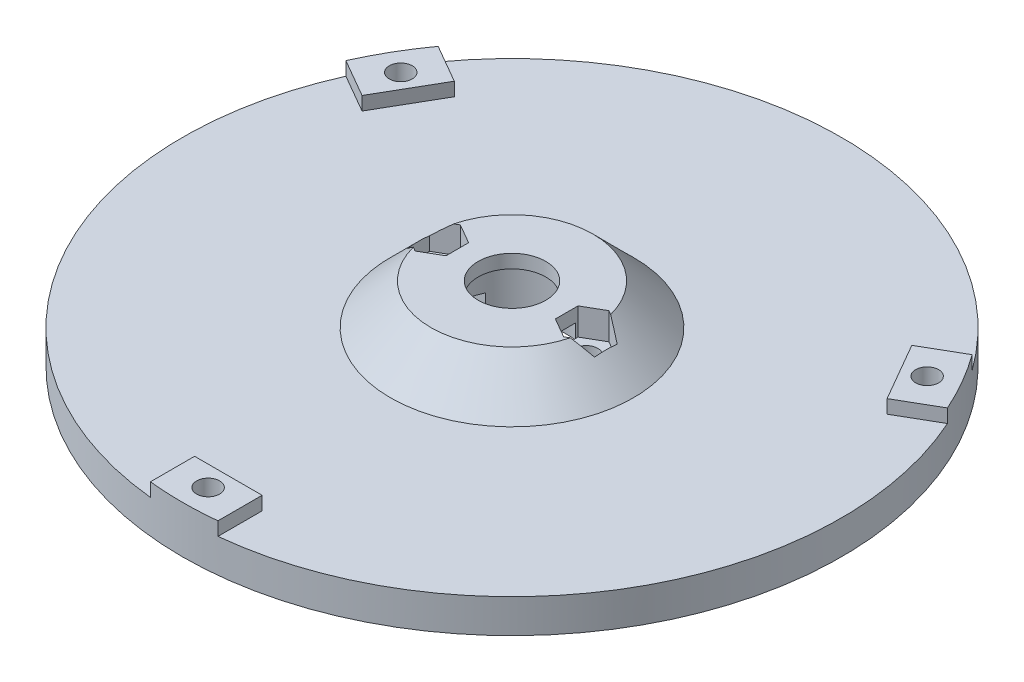
from build123d import *

# Parameters (mm, degrees)
CROQUIS2_W              = 30.6
CROQUIS2_H              = 7
CORTAR_EXTRUIR1_DEPTH   = 4
CROQUIS3_R              = 1.7
CORTAR_EXTRUIR2_DEPTH   = 13
CORTAR_EXTRUIR3_DEPTH   = 4
SALIENTE_EXTRUIR1_DEPTH = 2
CROQUIS6_R              = 1.7
CORTAR_EXTRUIR4_DEPTH   = 9
CROQUIS7_R              = 2.95
CORTAR_EXTRUIR5_DEPTH   = 3
MATRIZC1_COUNT          = 3


with BuildPart() as part:
    # Croquis1 → Revolución1 (revolve)
    with BuildSketch(Plane.XY):
        Polygon((5, 11), (12, 11), (18, 5), (48.8, 5), (48.8, 0), (8.2, 0), (8.2, 9), (5, 9), align=None)
    revolve(axis=Axis((0, 21.109727454, 0), (0, -1, 0)))

    # Croquis2 → Cortar-Extruir1 (cut)
    with BuildSketch(Plane.XZ):
        Rectangle(CROQUIS2_W, CROQUIS2_H)
    extrude(amount=-CORTAR_EXTRUIR1_DEPTH, mode=Mode.SUBTRACT)

    # Croquis3 → Cortar-Extruir2 (cut)
    with BuildSketch(Plane.XZ.offset(-4)):
        with Locations((-11, 0)):
            Circle(CROQUIS3_R)
        with Locations((11, 0)):
            Circle(CROQUIS3_R)
    extrude(amount=-CORTAR_EXTRUIR2_DEPTH, mode=Mode.SUBTRACT)

    # Croquis4 → Cortar-Extruir3 (cut)
    with BuildSketch(Plane(origin=(0, 11, 0), x_dir=(1, 0, 0), z_dir=(0, 1, 0))):
        Polygon((-11, 3.35), (-13.901185103, 1.675), (-13.901185103, -1.675), (-11, -3.35), (-8.098814897, -1.675), (-8.098814897, 1.675), align=None)
        Polygon((11, 3.35), (8.098814897, 1.675), (8.098814897, -1.675), (11, -3.35), (13.901185103, -1.675), (13.901185103, 1.675), align=None)
    extrude(amount=-CORTAR_EXTRUIR3_DEPTH, mode=Mode.SUBTRACT)

    # Croquis5 → Saliente-Extruir1 (add)
    with BuildSketch(Plane(origin=(0, 5, 0), x_dir=(1, 0, 0), z_dir=(0, 1, 0))):
        with BuildLine():
            Line((5, -42), (-5, -42))
            Line((-5, -42), (-5, -48.543176657))
            ThreePointArc((-5, -48.543176657), (0, -48.8), (5, -48.543176657))
            Line((5, -48.543176657), (5, -42))
        make_face()
    saliente_extruir1 = extrude(amount=SALIENTE_EXTRUIR1_DEPTH)

    # Croquis6 → Cortar-Extruir4 (cut)
    with BuildSketch(Plane(origin=(0, 7, 0), x_dir=(1, 0, 0), z_dir=(0, 1, 0))):
        with Locations((0, -45)):
            Circle(CROQUIS6_R)
    cortar_extruir4 = extrude(amount=-CORTAR_EXTRUIR4_DEPTH, mode=Mode.SUBTRACT)

    # Croquis7 → Cortar-Extruir5 (cut)
    with BuildSketch(Plane.XZ):
        with Locations((0, 45)):
            Circle(CROQUIS7_R)
    cortar_extruir5 = extrude(amount=-CORTAR_EXTRUIR5_DEPTH, mode=Mode.SUBTRACT)

    # MatrizC1: Saliente-Extruir1, Cortar-Extruir4, Cortar-Extruir5 ×3 about axis
    matrizc1_axis = Axis((0, 0, 0), (0, 1, 0))
    for i in range(1, MATRIZC1_COUNT):
        add(saliente_extruir1.rotate(matrizc1_axis, i * 360 / MATRIZC1_COUNT))
        add(cortar_extruir4.rotate(matrizc1_axis, i * 360 / MATRIZC1_COUNT), mode=Mode.SUBTRACT)
        add(cortar_extruir5.rotate(matrizc1_axis, i * 360 / MATRIZC1_COUNT), mode=Mode.SUBTRACT)


solid = part.part
